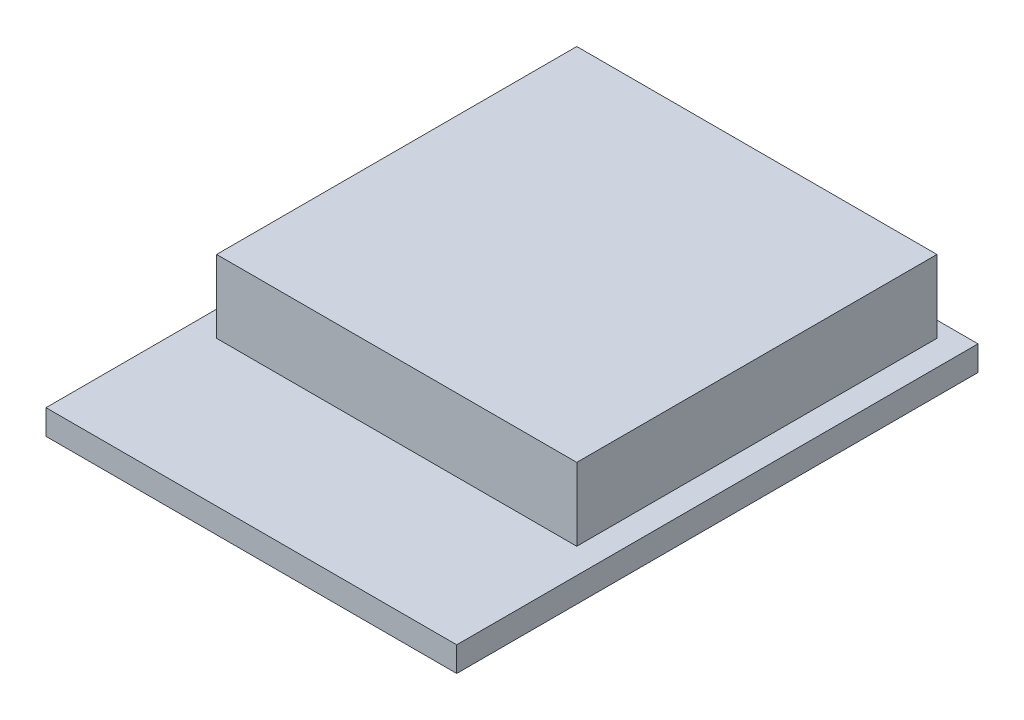
from build123d import *

# Parameters (mm, degrees)
SKETCH1_W           = 13
SKETCH1_H           = 16.5
BOSS_EXTRUDE1_DEPTH = 0.7874
SKETCH2_W           = 11.4
SKETCH2_H           = 11.4
BOSS_EXTRUDE2_DEPTH = 2.3


with BuildPart() as part:
    # Sketch1 → Boss-Extrude1 (new body)
    with BuildSketch(Plane(origin=(0, 0, 0), x_dir=(1, 0, 0), z_dir=(0, 1, 0))):
        Rectangle(SKETCH1_W, SKETCH1_H)
    extrude(amount=BOSS_EXTRUDE1_DEPTH)

    # Sketch2 → Boss-Extrude2 (add)
    with BuildSketch(Plane(origin=(0, 0.7874, 0), x_dir=(1, 0, 0), z_dir=(0, 1, 0))):
        with Locations((0, 2.05)):
            Rectangle(SKETCH2_W, SKETCH2_H)
    extrude(amount=BOSS_EXTRUDE2_DEPTH)


solid = part.part
